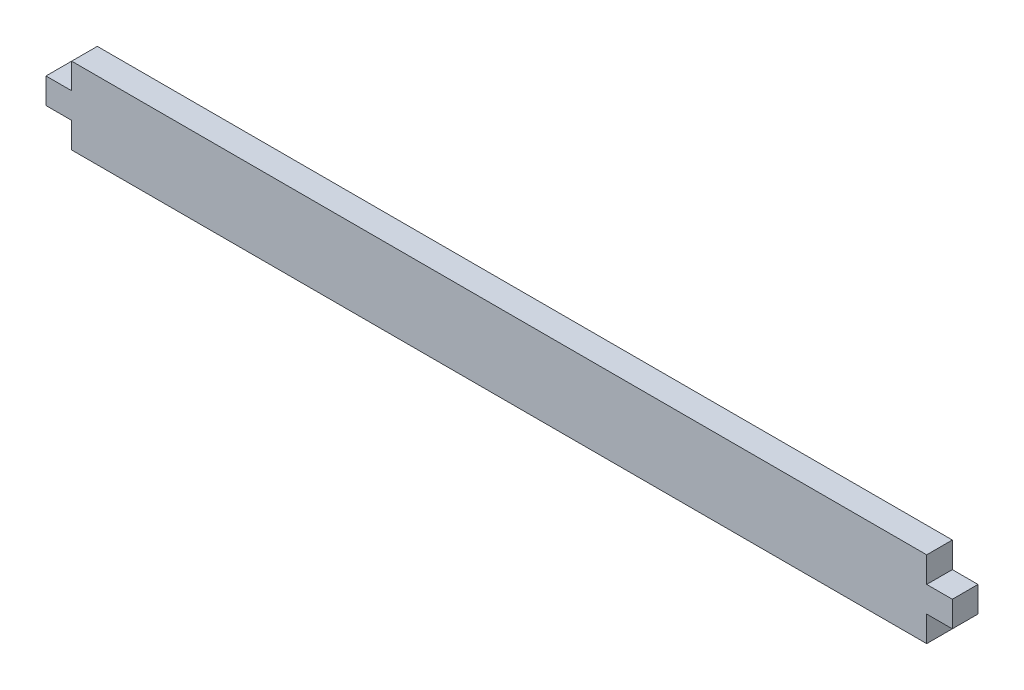
from build123d import *

# Parameters (mm, degrees)
SALIENTE_EXTRUIR1_DEPTH = 3


with BuildPart() as part:
    # Croquis1 → Saliente-Extruir1 (new body)
    with BuildSketch(Plane.XY):
        Polygon((0, 0), (100, 0), (100, 3), (103, 3), (103, 6), (100, 6), (100, 9), (0, 9), (0, 6), (-3, 6), (-3, 3), (0, 3), align=None)
    extrude(amount=SALIENTE_EXTRUIR1_DEPTH)


solid = part.part
